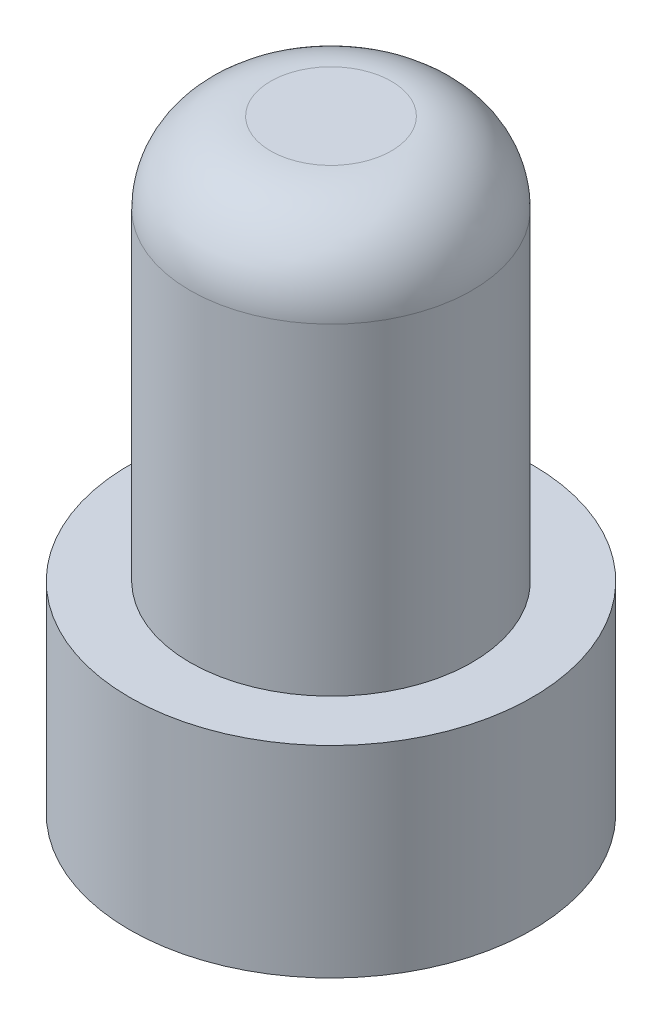
from build123d import *

# Parameters (mm, degrees)
SKETCH1_R           = 2.5
BOSS_EXTRUDE1_DEPTH = 2.5
SKETCH2_R           = 1.75
BOSS_EXTRUDE2_DEPTH = 5
FILLET1_R           = 1


with BuildPart() as part:
    # Sketch1 → Boss-Extrude1 (new body)
    with BuildSketch(Plane(origin=(0, 0, 0), x_dir=(1, 0, 0), z_dir=(0, 1, 0))):
        Circle(SKETCH1_R)
    extrude(amount=BOSS_EXTRUDE1_DEPTH)

    # Sketch2 → Boss-Extrude2 (add)
    with BuildSketch(Plane(origin=(0, 2.5, 0), x_dir=(1, 0, 0), z_dir=(0, 1, 0))):
        Circle(SKETCH2_R)
    extrude(amount=BOSS_EXTRUDE2_DEPTH)

    # Fillet1
    fillet1_edges = [part.edges().sort_by_distance(p)[0] for p in [
        (-1.75, 7.5, 0),
    ]]
    fillet(fillet1_edges, radius=FILLET1_R)


solid = part.part
